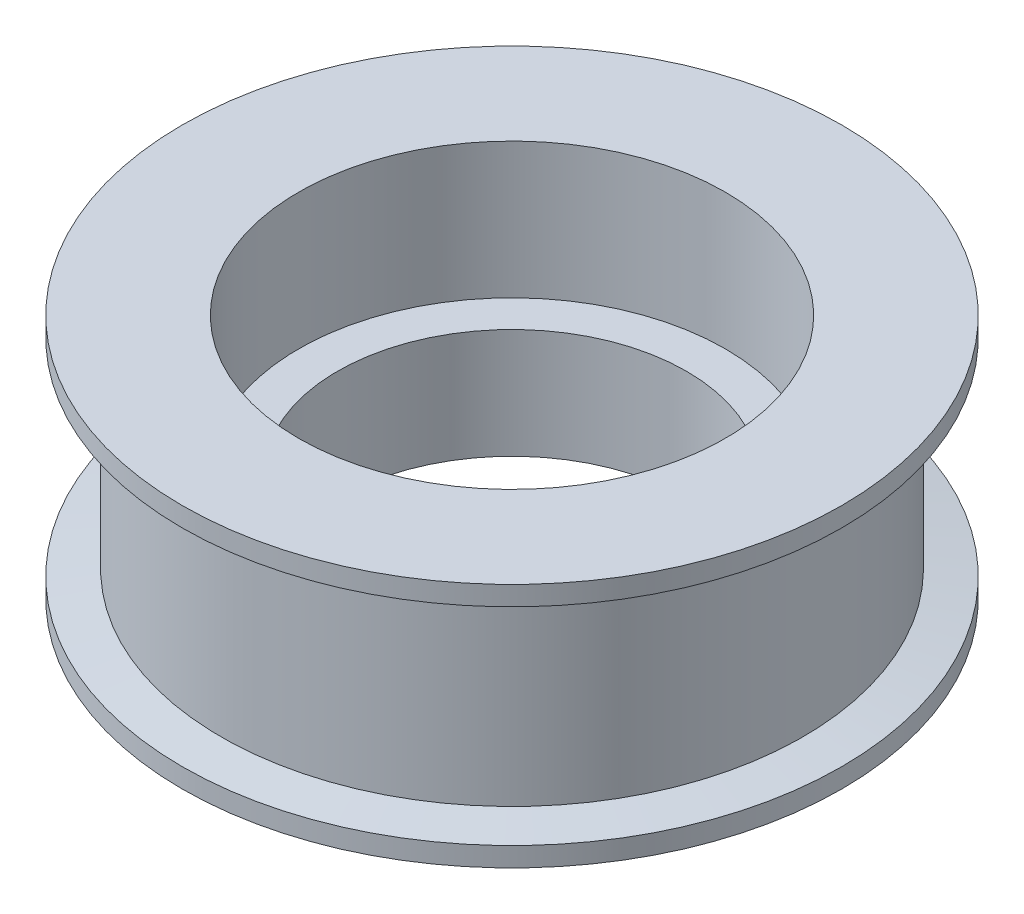
from build123d import *

# Parameters (mm, degrees)
SKETCH1_R           = 15
SKETCH1_R_2         = 11
BOSS_EXTRUDE1_DEPTH = 11.66


with BuildPart() as part:
    # Sketch1 → Boss-Extrude1 (new body)
    with BuildSketch(Plane(origin=(0, 0, 0), x_dir=(1, 0, 0), z_dir=(0, 1, 0))):
        Circle(SKETCH1_R)
        Circle(SKETCH1_R_2, mode=Mode.SUBTRACT)
    extrude(amount=BOSS_EXTRUDE1_DEPTH)

    # Sketch2 → Revolve1 (revolve)
    with BuildSketch(Plane.XY):
        Polygon((15, 11.66), (17, 11.66), (17, 10.66), (15, 10.33), align=None)
        Polygon((15, 0.33), (17, 0), (17, -1), (15, -1), (9, -1), (9, 0.33), (9, 4.66), (15, 4.66), align=None)
    revolve(axis=Axis((0, 0, 0), (0, 1, 0)))


solid = part.part
